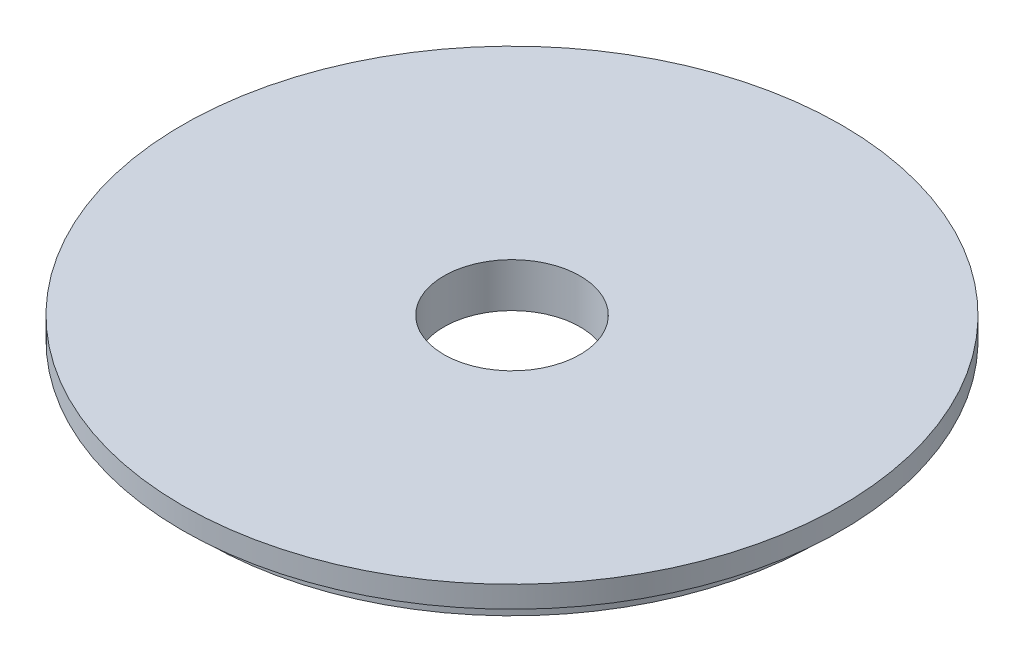
from build123d import *


with BuildPart() as part:
    # Sketch1 → Revolve1 (revolve)
    with BuildSketch(Plane.XY):
        Polygon((-9.525, 0), (-46.0756, 0), (-46.0756, -3.0226), (-42.7482, -3.0226), (-42.7482, -6.1722), (-9.525, -6.1722), align=None)
    revolve(axis=Axis((0, 0, 0), (0, -1, 0)))


solid = part.part
